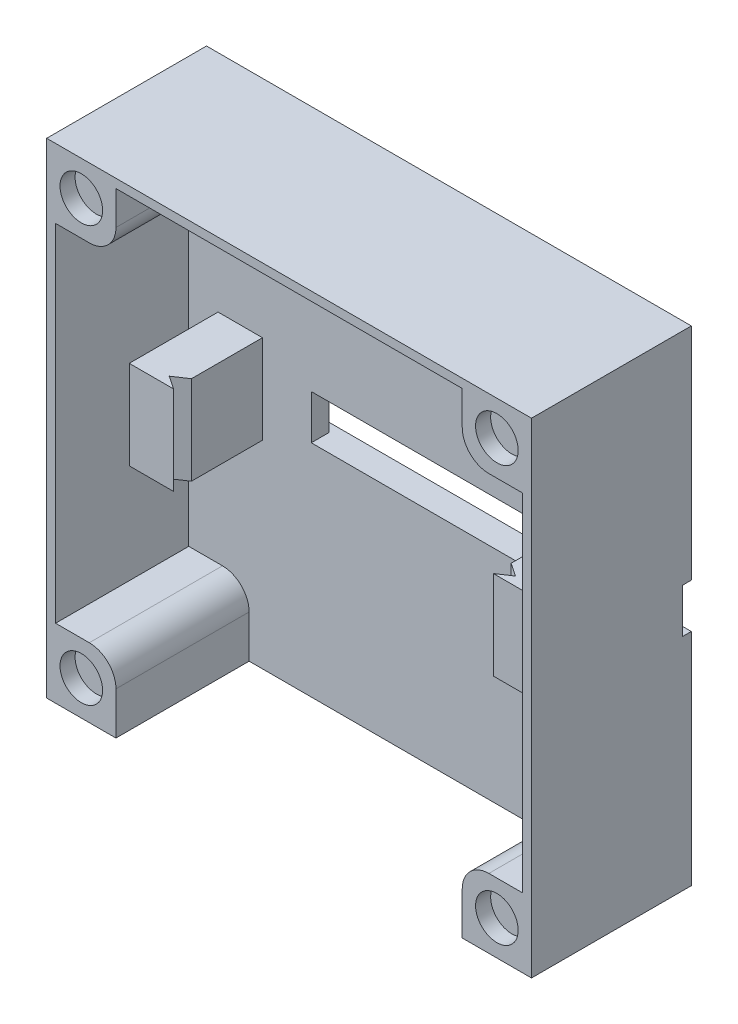
from build123d import *

# Parameters (mm, degrees)
SKICA1_W                 = 54.6
SKICA1_H                 = 54.6
P_IDAT_VYSUNUT_M2_DEPTH  = 3
SKICA4_W                 = 25
SKICA4_H                 = 5
ODEBRAT_VYSUNUT_M1_DEPTH = 2
SKICA5_W                 = 54.6
SKICA5_H                 = 5
ODEBRAT_VYSUNUT_M3_DEPTH = 1
SKICA10_W                = 5
SKICA10_H                = 10
P_IDAT_VYSUNUT_M6_DEPTH  = 10
ODEBRAT_VYSUNUT_M6_DEPTH = 10
P_IDAT_VYSUNUT_M9_DEPTH  = 15
SKICA17_R                = 2
ODEBRAT_VYSUNUT_M8_DEPTH = 4
SKICA19_W                = 7.8
SKICA19_H                = 7.8
P_IDAT_VYSUNUT_M10_DEPTH = 18
SKICA20_R                = 2.4
ODEBRAT_VYSUNUT_M9_DEPTH = 1.7
ZAOBLIT1_R               = 3


with BuildPart() as part:
    # Skica1 → Přidat vysunutím2 (new body)
    with BuildSketch(Plane.XY):
        Rectangle(SKICA1_W, SKICA1_H)
    extrude(amount=P_IDAT_VYSUNUT_M2_DEPTH)

    # Skica4 → Odebrat vysunutím1 (cut)
    with BuildSketch(Plane.XY.offset(3)):
        Rectangle(SKICA4_W, SKICA4_H)
    extrude(amount=-ODEBRAT_VYSUNUT_M1_DEPTH, mode=Mode.SUBTRACT)

    # Skica5 → Odebrat vysunutím3 (cut)
    with BuildSketch(Plane(origin=(0, 0, 0), x_dir=(-1, 0, 0), z_dir=(0, 0, -1))):
        Rectangle(SKICA5_W, SKICA5_H)
    extrude(amount=-ODEBRAT_VYSUNUT_M3_DEPTH, mode=Mode.SUBTRACT)

    # Skica10 → Přidat vysunutím6 (add)
    with BuildSketch(Plane.XY.offset(3)):
        with Locations((-20.5, 0)):
            Rectangle(SKICA10_W, SKICA10_H)
        with Locations((20.5, 0)):
            Rectangle(SKICA10_W, SKICA10_H)
    extrude(amount=P_IDAT_VYSUNUT_M6_DEPTH)

    # Skica12 → Odebrat vysunutím6 (cut)
    with BuildSketch(Plane(origin=(0, 5, 0), x_dir=(1, 0, 0), z_dir=(0, 1, 0))):
        Polygon((-18, -13), (-18, -11), (-19.5, -12), align=None)
        Polygon((18, -13), (18, -11), (19.5, -12), align=None)
    extrude(amount=-ODEBRAT_VYSUNUT_M6_DEPTH, mode=Mode.SUBTRACT)

    # Skica14 → Přidat vysunutím9 (add)
    with BuildSketch(Plane.XY.offset(3)):
        Polygon((27.3, 27.3), (-27.3, 27.3), (-27.3, -27.3), (-26.3, -27.3), (-26.3, 26.3), (26.3, 26.3), (26.3, -27.3), (27.3, -27.3), align=None)
    extrude(amount=P_IDAT_VYSUNUT_M9_DEPTH)

    # Skica17 → Odebrat vysunutím8 (cut)
    with BuildSketch(Plane(origin=(0, 0, 1), x_dir=(-1, 0, 0), z_dir=(0, 0, -1))):
        with Locations((-20.3, 0)):
            Circle(SKICA17_R)
        with Locations((20.3, 0)):
            Circle(SKICA17_R)
    extrude(amount=-ODEBRAT_VYSUNUT_M8_DEPTH, mode=Mode.SUBTRACT)

    # Skica19 → Přidat vysunutím10 (add)
    with BuildSketch(Plane(origin=(0, 0, 0), x_dir=(-1, 0, 0), z_dir=(0, 0, -1))):
        with Locations((-23.4, 23.4)):
            Rectangle(SKICA19_W, SKICA19_H)
        with Locations((23.4, 23.4)):
            Rectangle(SKICA19_W, SKICA19_H)
        with Locations((-23.4, -23.4)):
            Rectangle(SKICA19_W, SKICA19_H)
        with Locations((23.4, -23.4)):
            Rectangle(SKICA19_W, SKICA19_H)
    extrude(amount=-P_IDAT_VYSUNUT_M10_DEPTH)

    # Skica20 → Odebrat vysunutím9 (cut)
    with BuildSketch(Plane.XY.offset(18)):
        with Locations((-23.4, -23.4)):
            Circle(SKICA20_R)
        with Locations((-23.4, 23.4)):
            Circle(SKICA20_R)
        with Locations((23.400280565, 23.4)):
            Circle(SKICA20_R)
        with Locations((23.400280565, -23.4)):
            Circle(SKICA20_R)
    extrude(amount=-ODEBRAT_VYSUNUT_M9_DEPTH, mode=Mode.SUBTRACT)

    # Zaoblit1
    zaoblit1_edges = [part.edges().sort_by_distance(p)[0] for p in [
        (19.5, 19.5, 10.5),
        (-19.5, 19.5, 10.5),
        (19.5, -19.5, 10.5),
        (-19.5, -19.5, 10.5),
    ]]
    fillet(zaoblit1_edges, radius=ZAOBLIT1_R)


solid = part.part
